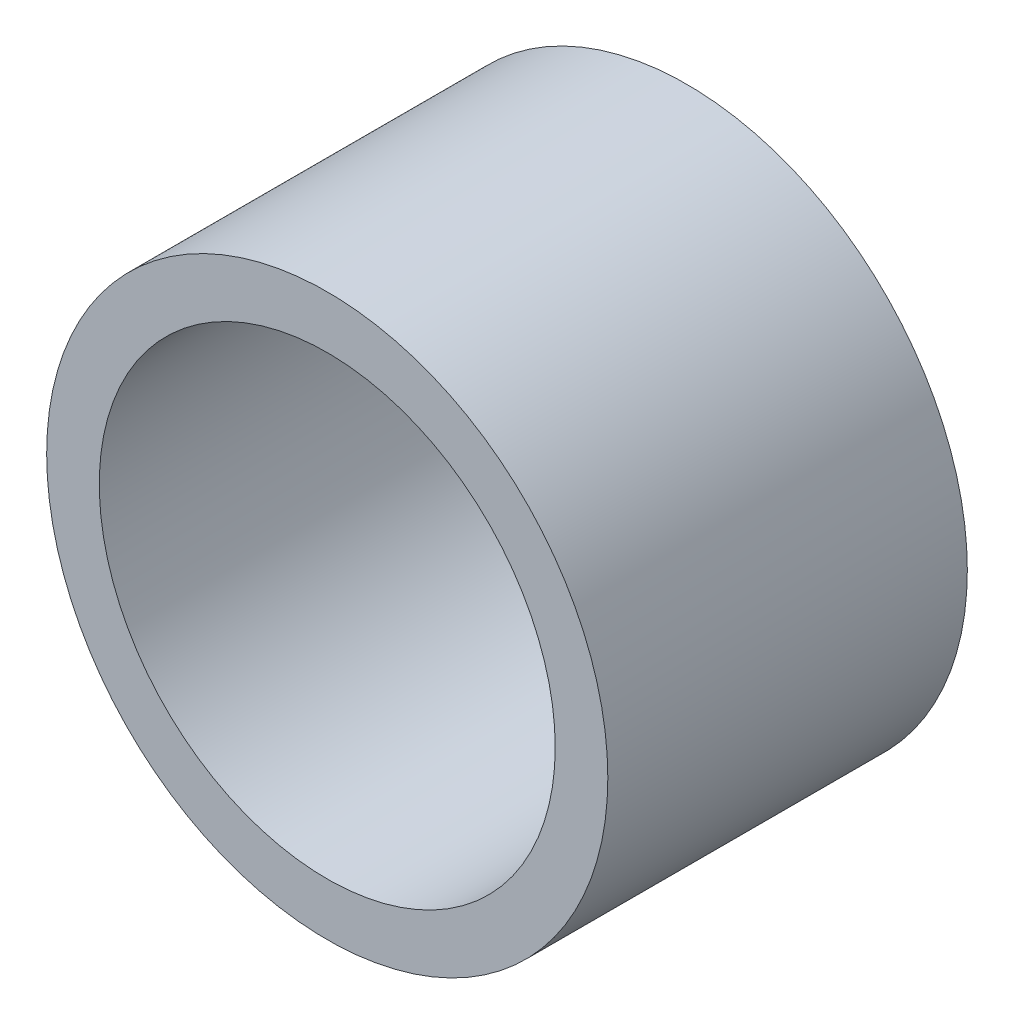
from build123d import *

# Parameters (mm, degrees)
SKETCH_1_R      = 16
SKETCH_1_R_2    = 13
EXTRUDE_1_DEPTH = 20.5


with BuildPart() as part:
    # 草图1 → 凸台-拉伸1 (new body)
    with BuildSketch(Plane.XY):
        Circle(SKETCH_1_R)
        Circle(SKETCH_1_R_2, mode=Mode.SUBTRACT)
    extrude(amount=EXTRUDE_1_DEPTH)


solid = part.part
